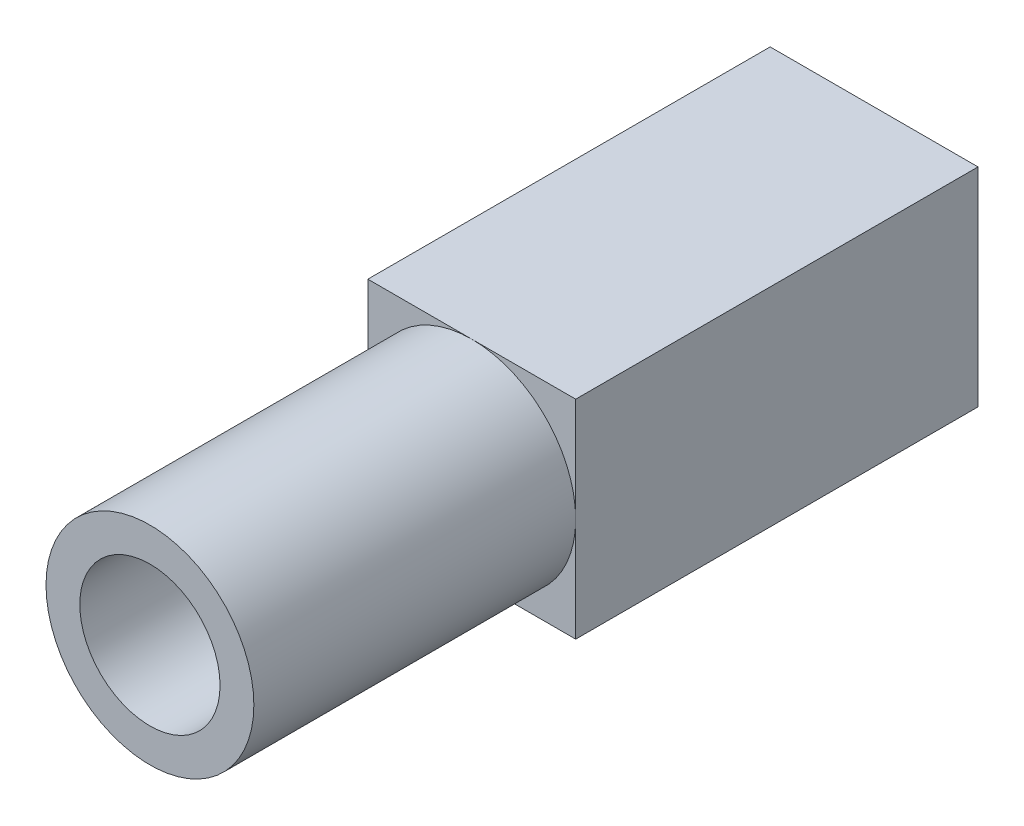
from build123d import *

# Parameters (mm, degrees)
SKETCH1_R           = 3.875
SKETCH1_R_2         = 2.615
BOSS_EXTRUDE1_DEPTH = 22
BOSS_EXTRUDE2_DEPTH = 10
SKETCH4_W           = 7.75
SKETCH4_H           = 7.75
BOSS_EXTRUDE3_DEPTH = 5


with BuildPart() as part:
    # Sketch1 → Boss-Extrude1 (new body)
    with BuildSketch(Plane.XY):
        Circle(SKETCH1_R)
        Circle(SKETCH1_R_2, mode=Mode.SUBTRACT)
    extrude(amount=BOSS_EXTRUDE1_DEPTH)

    # Sketch2 → Boss-Extrude2 (add)
    with BuildSketch(Plane.XY.offset(10)):
        with BuildLine():
            Line((0, 3.875), (-3.875, 3.875))
            Line((-3.875, 3.875), (-3.875, 0))
            ThreePointArc((-3.875, 0), (-2.740038777, 2.740038777), (0, 3.875))
        make_face()
        with BuildLine():
            ThreePointArc((0, -3.875), (-2.740038777, -2.740038777), (-3.875, 0))
            Line((-3.875, 0), (-3.875, -3.875))
            Line((-3.875, -3.875), (0, -3.875))
        make_face()
        with BuildLine():
            Line((3.875, 3.875), (0, 3.875))
            ThreePointArc((0, 3.875), (2.740038777, 2.740038777), (3.875, 0))
            Line((3.875, 0), (3.875, 3.875))
        make_face()
        with BuildLine():
            Line((3.875, -3.875), (3.875, 0))
            ThreePointArc((3.875, 0), (2.740038777, -2.740038777), (0, -3.875))
            Line((0, -3.875), (3.875, -3.875))
        make_face()
    extrude(amount=-BOSS_EXTRUDE2_DEPTH)

    # Sketch4 → Boss-Extrude3 (add)
    with BuildSketch(Plane(origin=(0, 0, 0), x_dir=(-1, 0, 0), z_dir=(0, 0, -1))):
        Rectangle(SKETCH4_W, SKETCH4_H)
    extrude(amount=BOSS_EXTRUDE3_DEPTH)


solid = part.part
